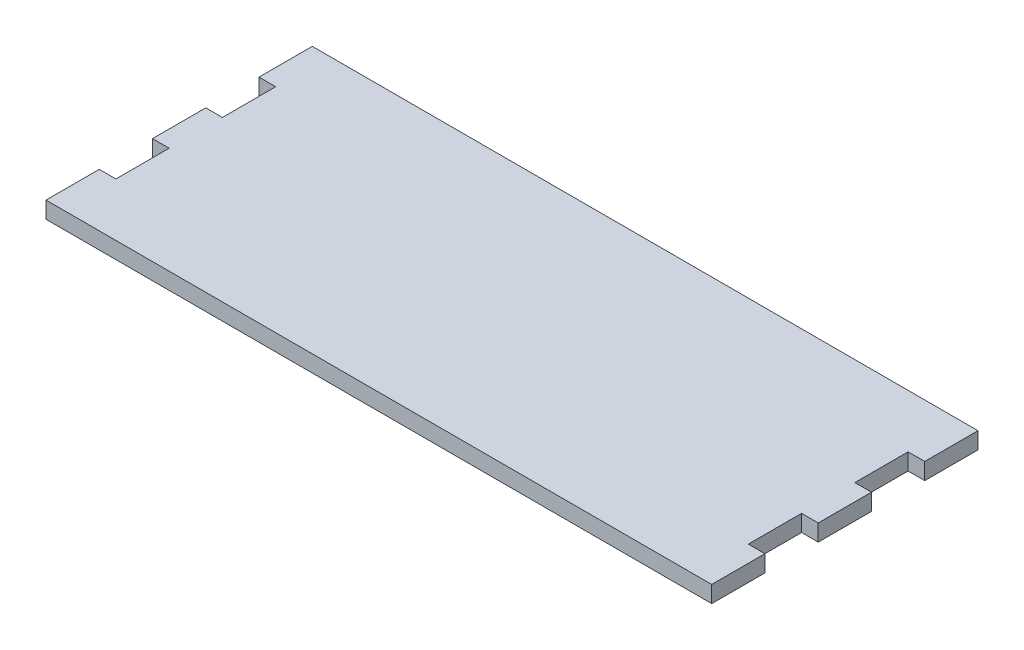
from build123d import *

# Parameters (mm, degrees)
BOSS_EXTRUDE1_DEPTH = 5


with BuildPart() as part:
    # Sketch1 → Boss-Extrude1 (new body)
    with BuildSketch(Plane(origin=(0, 0, 0), x_dir=(1, 0, 0), z_dir=(0, 1, 0))):
        Polygon((-95, 24), (-95, 8), (-100, 8), (-100, -8), (-95, -8), (-95, -24), (-100, -24), (-100, -40), (100, -40), (100, -24), (95, -24), (95, -8), (100, -8), (100, 8), (95, 8), (95, 24), (100, 24), (100, 40), (-100, 40), (-100, 24), align=None)
    extrude(amount=BOSS_EXTRUDE1_DEPTH)


solid = part.part
